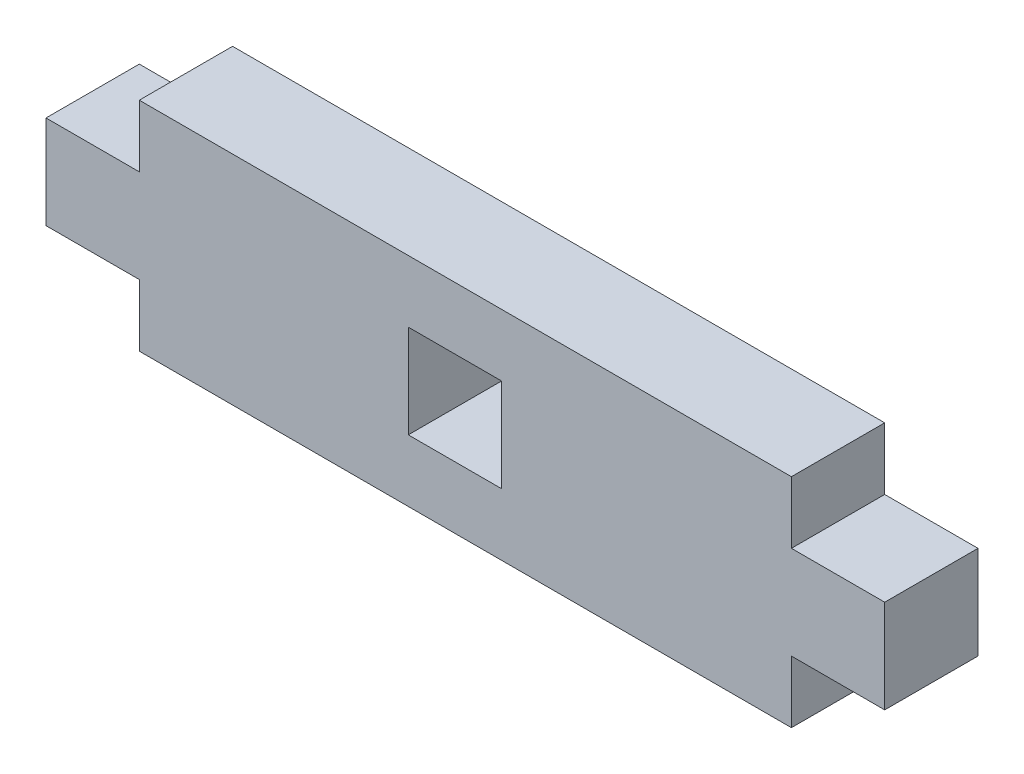
from build123d import *

# Parameters (mm, degrees)
BOSS_EXTRUDE1_DEPTH = 5.15
SKETCH3_W           = 5.15
SKETCH3_H           = 5.15
CUT_EXTRUDE1_DEPTH  = 6.15


with BuildPart() as part:
    # Sketch2 → Boss-Extrude1 (new body)
    with BuildSketch(Plane.XY):
        Polygon((0, 3.425), (0, 8.575), (5.15, 8.575), (5.15, 12), (41.15, 12), (41.15, 8.575), (46.3, 8.575), (46.3, 3.425), (41.15, 3.425), (41.15, 0), (5.15, 0), (5.15, 3.425), align=None)
    extrude(amount=BOSS_EXTRUDE1_DEPTH)

    # Sketch3 → Cut-Extrude1 (cut, through all)
    with BuildSketch(Plane.XY.offset(5.15)):
        with Locations((22.575, 6)):
            Rectangle(SKETCH3_W, SKETCH3_H)
    extrude(amount=-CUT_EXTRUDE1_DEPTH, mode=Mode.SUBTRACT)


solid = part.part
